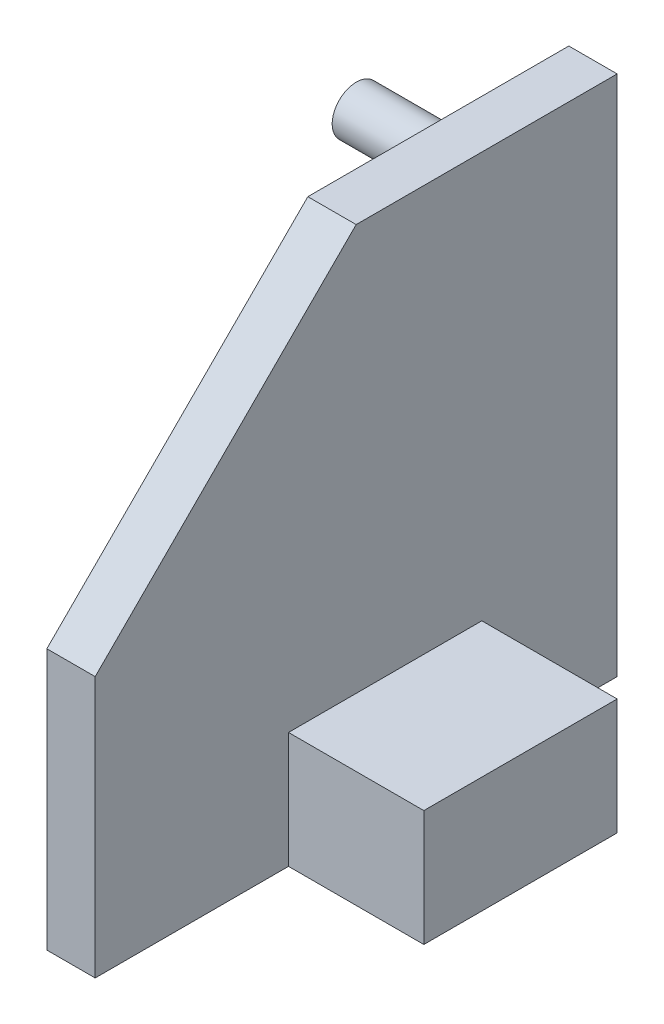
from build123d import *

# Parameters (mm, degrees)
SKETCH1_W           = 27
SKETCH1_H           = 27
BOSS_EXTRUDE1_DEPTH = 2.5
SKETCH2_W           = 10
SKETCH2_H           = 6
BOSS_EXTRUDE2_DEPTH = 7
SKETCH3_R           = 1.25
BOSS_EXTRUDE3_DEPTH = 8.5
CUT_EXTRUDE1_DEPTH  = 9.5


with BuildPart() as part:
    # Sketch1 → Boss-Extrude1 (new body)
    with BuildSketch(Plane(origin=(0, 0, 0), x_dir=(0, 0, -1), z_dir=(1, 0, 0))):
        with Locations((-28.770960436, 13.5)):
            Rectangle(SKETCH1_W, SKETCH1_H)
    extrude(amount=BOSS_EXTRUDE1_DEPTH)

    # Sketch2 → Boss-Extrude2 (add)
    with BuildSketch(Plane(origin=(2.5, 0, 0), x_dir=(0, 0, -1), z_dir=(1, 0, 0))):
        with Locations((-27.270960436, 3)):
            Rectangle(SKETCH2_W, SKETCH2_H)
    extrude(amount=BOSS_EXTRUDE2_DEPTH)

    # Sketch3 → Boss-Extrude3 (add)
    with BuildSketch(Plane(origin=(2.5, 0, 0), x_dir=(0, 0, -1), z_dir=(1, 0, 0))):
        with Locations((-20.260960436, 23.63)):
            Circle(SKETCH3_R)
    extrude(amount=-BOSS_EXTRUDE3_DEPTH)

    # Sketch4 → Cut-Extrude1 (cut, through all)
    with BuildSketch(Plane(origin=(2.5, 0, 0), x_dir=(0, 0, -1), z_dir=(1, 0, 0))):
        Polygon((-42.270960436, 13.5), (-28.770960436, 27), (-42.270960436, 27), align=None)
    extrude(amount=-CUT_EXTRUDE1_DEPTH, mode=Mode.SUBTRACT)


solid = part.part
